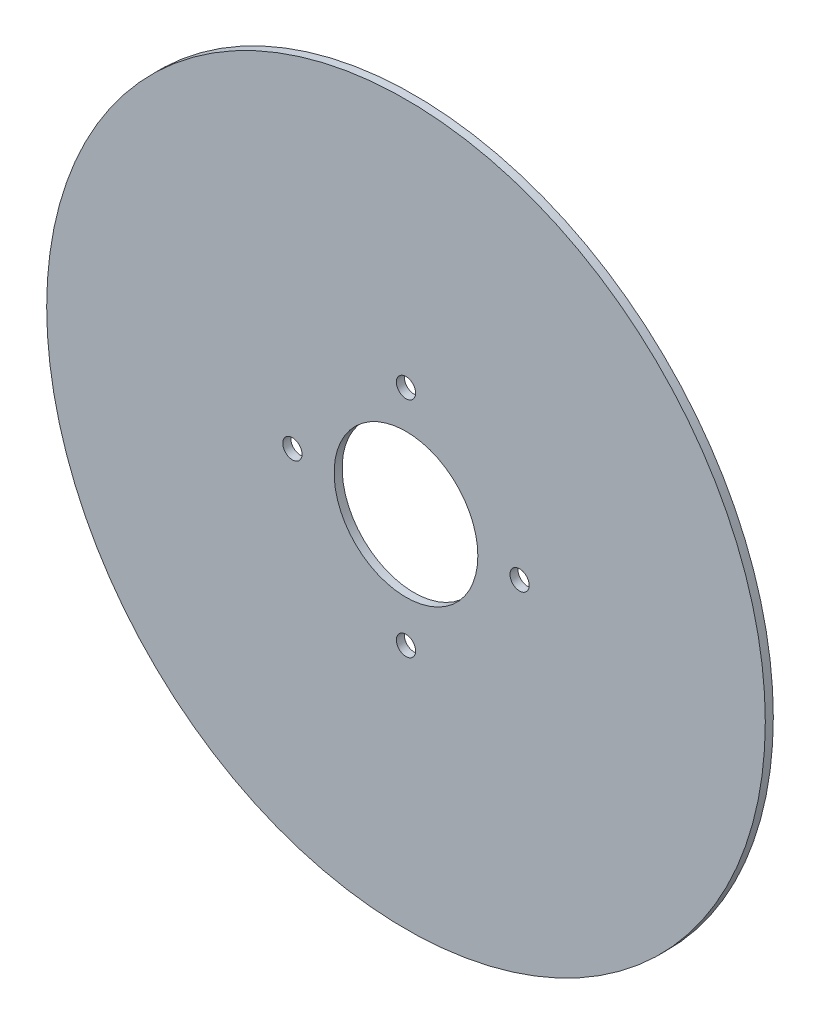
from build123d import *

# Parameters (mm, degrees)
SKETCH1_R      = 56
SKETCH1_R_2    = 11.2
EXTRUDE1_DEPTH = 1.25
SKETCH2_R      = 1.5
EXTRUDE2_DEPTH = 1.25


with BuildPart() as part:
    # Sketch1 → Extrude1 (new body)
    with BuildSketch(Plane.XY):
        Circle(SKETCH1_R)
        Circle(SKETCH1_R_2, mode=Mode.SUBTRACT)
    extrude(amount=EXTRUDE1_DEPTH)

    # Sketch2 → Extrude2 (cut)
    with BuildSketch(Plane.XY.offset(1.25)):
        with Locations((17.7, 0)):
            Circle(SKETCH2_R)
        with Locations((0, -17.7)):
            Circle(SKETCH2_R)
        with Locations((-17.7, 0)):
            Circle(SKETCH2_R)
        with Locations((0, 17.1)):
            Circle(SKETCH2_R)
    extrude(amount=-EXTRUDE2_DEPTH, mode=Mode.SUBTRACT)


solid = part.part
